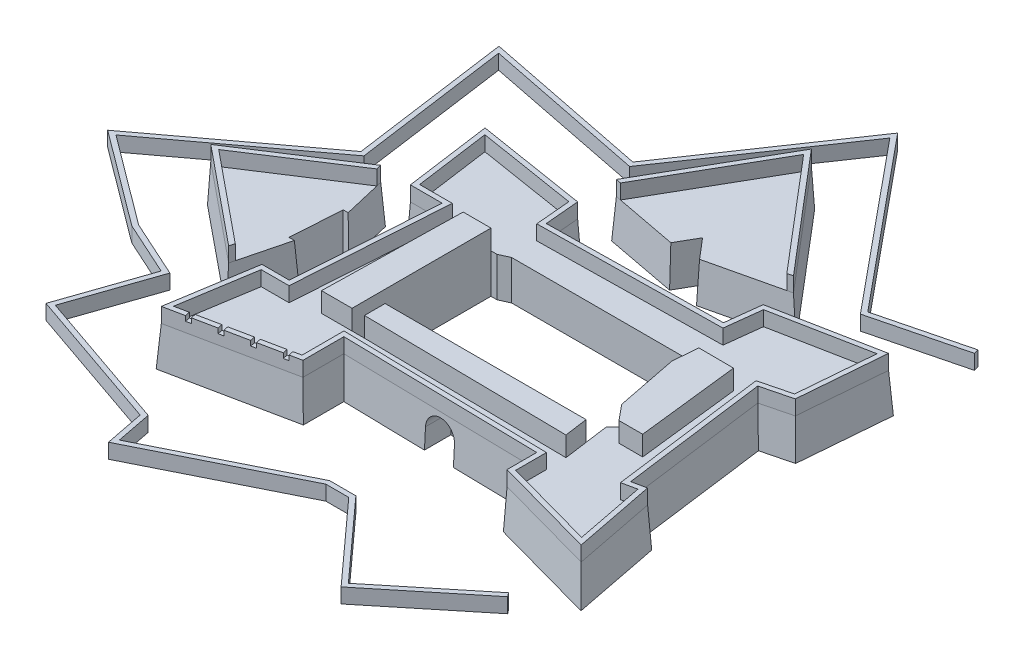
from build123d import *

# Parameters (mm, degrees)
BOSS_EXTRUDE2_DEPTH           = 4000
BOSS_EXTRUDE2_DRAFT           = 3
BOSS_EXTRUDE2_PROFILE_2_DEPTH = 4000
BOSS_EXTRUDE2_PROFILE_2_DRAFT = 3
BOSS_EXTRUDE2_PROFILE_3_DEPTH = 4000
BOSS_EXTRUDE2_PROFILE_3_DRAFT = 3
CUT_EXTRUDE8_DEPTH            = 90232.910730358
CUT_EXTRUDE8_DEPTH_BACK       = 9000
BOSS_EXTRUDE8_DEPTH           = 1500
BOSS_EXTRUDE3_START           = 4000
BOSS_EXTRUDE3_DEPTH           = 1500
BOSS_EXTRUDE4_START           = 4000
BOSS_EXTRUDE4_DEPTH           = 1500
BOSS_EXTRUDE5_START           = 4000
BOSS_EXTRUDE5_DEPTH           = 1500
CUT_EXTRUDE9_DEPTH            = 11000
SKETCH12_W                    = 500
SKETCH12_H                    = 500
CUT_EXTRUDE10_DEPTH           = 500
LPATTERN1_COUNT               = 4
LPATTERN1_PITCH               = 2800
BOSS_EXTRUDE7_DEPTH           = 6000


with BuildPart() as part:
    # Sketch5 → Boss-Extrude2 (with draft: the straight prism first)
    with BuildSketch(Plane(origin=(0, 0, 0), x_dir=(1, 0, 0), z_dir=(0, 1, 0))):
        Polygon((24221.147231465, 12812.777238771), (36613.382745291, 15360.254637852), (36613.382745291, 19466.636116967), (56159.669846807, 19081.326574374), (56159.669846807, 16120.695652503), (67033.976356316, 13116.953644631), (65285.659888842, 22049.569248776), (63878.146145515, 21747.95916092), (61977.043608887, 36196.338439289), (64980.785616759, 36956.77945394), (65747.322139372, 46120.093680485), (54681.474863666, 43954.255153895), (54258.567310179, 40378.76401987), (36920.512176137, 40112.609664742), (36613.382745291, 43579.189822963), (24972.576970271, 45446.698770827), (26254.199807291, 36196.338439289), (29430.168181824, 36196.338439289), (28473.81693967, 22090.157617513), (25709.497024846, 22090.157617513), align=None)
    extrude(amount=BOSS_EXTRUDE2_DEPTH)
    # Boss-Extrude2: the draft: its side faces are tilted about the plane it starts from
    boss_extrude2_sides = [part.faces().sort_by_distance(p)[0] for p in [
        (30417.264988378, 2000, -14086.515938311),
        (36613.382745291, 2000, -17413.445377409),
        (46386.526296049, 2000, -19273.981345671),
        (56159.669846807, 2000, -17601.011113438),
        (61596.823101562, 2000, -14618.824648567),
        (66159.818122579, 2000, -17583.261446704),
        (64581.903017178, 2000, -21898.764204848),
        (62927.594877201, 2000, -28972.148800105),
        (63478.914612823, 2000, -36576.558946615),
        (65364.053878065, 2000, -41538.436567213),
        (60214.398501519, 2000, -45037.17441719),
        (54470.021086923, 2000, -42166.509586883),
        (45589.539743158, 2000, -40245.686842306),
        (36766.947460714, 2000, -41845.899743852),
        (30792.979857781, 2000, -44512.944296895),
        (25613.388388781, 2000, -40821.518605058),
        (27842.183994557, 2000, -36196.338439289),
        (28951.992560747, 2000, -29143.248028401),
        (27091.656982258, 2000, -22090.157617513),
        (24965.322128155, 2000, -17451.467428142),
    ]]
    draft(boss_extrude2_sides, Plane(origin=(0, 0, 0), x_dir=(1, 0, 0), z_dir=(0, 1, 0)), BOSS_EXTRUDE2_DRAFT)

    # Sketch5_4 → Cut-Extrude8 (cut, two sides)
    with BuildSketch(Plane(origin=(0, 0, 0), x_dir=(1, 0, 0), z_dir=(0, 1, 0))) as cut_extrude8_sk:
        Polygon((35428.968084809, 22093.341525096), (31723.721045337, 22093.341525096), (32001.728794941, 36196.338439289), (35428.968084809, 36196.338439289), align=None)
        Polygon((36084.02706002, 22093.341525096), (35428.968084809, 22093.341525096), (35428.968084809, 36196.338439289), (36458.730662276, 36657.954872095), (54258.567310179, 36657.954872095), (55973.233378537, 36196.338439289), (55973.233378537, 34396.808595444), (56951.330931415, 27337.200618605), (56159.669846807, 26560.044676759), (36084.02706002, 26560.044676759), align=None)
        Polygon((59443.059424266, 36196.338439289), (60646.271833248, 25773.58180428), (58239.847015285, 25773.58180428), (56951.330931415, 27337.200618605), (55973.233378537, 34396.808595444), (55973.233378537, 36196.338439289), align=None)
        Polygon((56817.379343917, 21812.899365358), (36084.02706002, 22093.341525096), (36084.02706002, 26560.044676759), (56159.669846807, 26560.044676759), align=None)
    extrude(amount=CUT_EXTRUDE8_DEPTH, mode=Mode.SUBTRACT)
    extrude(cut_extrude8_sk.sketch, amount=-CUT_EXTRUDE8_DEPTH_BACK, mode=Mode.SUBTRACT)

    # Sketch7_4 → Boss-Extrude4 (add)
    with BuildSketch(Plane(origin=(0, 0, 0), x_dir=(1, 0, 0), z_dir=(0, 1, 0)).offset(BOSS_EXTRUDE4_START)):
        Polygon((28669.716997515, 21880.526500381), (25888.177990487, 21880.526500381), (24476.204351751, 13079.224152258), (36403.751628159, 15531.175382463), (36403.751628159, 19680.440349773), (56369.300963939, 19286.866028357), (56369.300963939, 16280.272060367), (66763.160475319, 13409.240936594), (65120.921538659, 21799.878114852), (63699.941915328, 21495.382481281), (61744.885798014, 36353.808972866), (64784.351704009, 37123.294012359), (65515.290885637, 45861.071279535), (54871.705572801, 43777.879043348), (54445.20057926, 40171.97318886), (36728.895454385, 39900.012364574), (36418.977542885, 43398.066197205), (25219.105564891, 45194.837102765), (26436.789304251, 36405.969556421), (29654.492797924, 36405.969556421), align=None)
        Polygon((35955.293512896, 42966.060614647), (25807.111291314, 44594.11123843), (26872.291197907, 36905.969556421), (30189.538880703, 36905.969556421), (29136.966470124, 21380.526500381), (26314.3574816, 21380.526500381), (25084.551823671, 13714.737899291), (35903.751628159, 15938.845643799), (35903.751628159, 20190.393823596), (56869.300963939, 19777.106830377), (56869.300963939, 16660.884466691), (66117.226120005, 14106.387657847), (64727.997166463, 21204.329282836), (63274.899506011, 20892.951212739), (61191.156432714, 36729.3985698), (64315.828911598, 37520.454893568), (64961.863377094, 45243.266049822), (55325.432843202, 43357.196959123), (54890.347443984, 39678.747674825), (36271.86234696, 39392.937596582), align=None, mode=Mode.SUBTRACT)
    extrude(amount=BOSS_EXTRUDE4_DEPTH)

    # Sketch9 → Cut-Extrude9 (cut)
    with BuildSketch(Plane.XY.offset(-30000)):
        with BuildLine():
            Line((44964.636947484, 0), (44964.636947484, 2000))
            ThreePointArc((44964.636947484, 2000), (46464.636947484, 3500), (47964.636947484, 2000))
            Line((47964.636947484, 2000), (47964.636947484, 0))
            Line((47964.636947484, 0), (44964.636947484, 0))
        make_face()
    extrude(amount=CUT_EXTRUDE9_DEPTH, mode=Mode.SUBTRACT)

    # Sketch12 → Cut-Extrude10 (cut)
    with BuildSketch(Plane(origin=(-1587.279743094, 0, -7721.342065621), x_dir=(0.9795173421549181, 0, -0.2013598182800262), z_dir=(0.20135981828002616, 0, 0.979517342154918))):
        with Locations((37340.818301027, 5250)):
            Rectangle(SKETCH12_W, SKETCH12_H)
    cut_extrude10 = extrude(amount=-CUT_EXTRUDE10_DEPTH, mode=Mode.SUBTRACT)

    # LPattern1: Cut-Extrude10 ×4
    with Locations(*[Vector(-0.9795173421549181, 0, 0.2013598182800262) * (i * LPATTERN1_PITCH) for i in range(1, LPATTERN1_COUNT)]):
        add(cut_extrude10, mode=Mode.SUBTRACT)

    # Sketch8 → Boss-Extrude7 (add)
    with BuildSketch(Plane(origin=(0, 0, 0), x_dir=(1, 0, 0), z_dir=(0, 1, 0))):
        Polygon((32001.728794941, 36196.338439289), (34821.189503531, 36196.338439289), (34821.189503531, 22093.341525096), (31723.721045337, 22093.341525096), align=None)
        Polygon((36084.02706002, 22093.341525096), (56817.379343917, 21812.899365358), (56488.524595362, 24186.472021059), (36084.02706002, 24186.472021059), align=None)
        Polygon((59443.059424266, 36196.338439289), (60646.271833248, 25773.58180428), (58239.847015285, 25773.58180428), (56951.330931415, 27337.200618605), (55694.285613264, 33692.829318225), (55908.720433738, 36213.706389818), align=None)
    extrude(amount=BOSS_EXTRUDE7_DEPTH)


with BuildPart() as body_2:
    # Sketch5 → Boss-Extrude2 profile 2 (with draft: the straight prism first)
    with BuildSketch(Plane(origin=(0, 0, 0), x_dir=(1, 0, 0), z_dir=(0, 1, 0))):
        Polygon((22700.265202163, 21443.78275506), (24202.136206099, 27337.200618605), (23612.794419744, 27337.200618605), (23916.970825604, 32089.956960174), (24487.301586593, 32089.956960174), (23346.640064616, 36956.77945394), (12396.289453642, 29846.655966953), align=None)
    extrude(amount=BOSS_EXTRUDE2_PROFILE_2_DEPTH)
    # Boss-Extrude2 profile 2: the draft: its side faces are tilted about the plane it starts from
    boss_extrude2_profile_2_sides = [body_2.faces().sort_by_distance(p)[0] for p in [
        (23451.200704131, 2000, -24390.491686832),
        (23907.465312921, 2000, -27337.200618605),
        (23764.882622674, 2000, -29713.578789389),
        (24202.136206099, 2000, -32089.956960174),
        (23916.970825604, 2000, -34523.368207057),
        (17871.464759129, 2000, -33401.717710447),
        (17548.277327902, 2000, -25645.219361007),
    ]]
    draft(boss_extrude2_profile_2_sides, Plane(origin=(0, 0, 0), x_dir=(1, 0, 0), z_dir=(0, 1, 0)), BOSS_EXTRUDE2_PROFILE_2_DRAFT)

    # Sketch7_6 → Boss-Extrude5 (add)
    with BuildSketch(Plane(origin=(0, 0, 0), x_dir=(1, 0, 0), z_dir=(0, 1, 0)).offset(BOSS_EXTRUDE5_START)):
        Polygon((23210.610198856, 36618.509706606), (12751.589675404, 29827.409575058), (22578.229585565, 21813.802858654), (22714.35680761, 22347.972970475), (13599.031187481, 29781.504195747), (23331.878959981, 36101.096325807), align=None)
    extrude(amount=BOSS_EXTRUDE5_DEPTH)


with BuildPart() as body_3:
    # Sketch5 → Boss-Extrude2 profile 3 (with draft: the straight prism first)
    with BuildSketch(Plane(origin=(0, 0, 0), x_dir=(1, 0, 0), z_dir=(0, 1, 0))):
        Polygon((36084.02706002, 47184.711100996), (43346.233299116, 45803.211873316), (44448.538693732, 47720.822016325), (46076.764033341, 45803.211873316), (54258.567310179, 47720.822016325), (43604.788694919, 60268.098758067), align=None)
    extrude(amount=BOSS_EXTRUDE2_PROFILE_3_DEPTH)
    # Boss-Extrude2 profile 3: the draft: its side faces are tilted about the plane it starts from
    boss_extrude2_profile_3_sides = [body_3.faces().sort_by_distance(p)[0] for p in [
        (39715.130179568, 2000, -46493.961487156),
        (43897.385996424, 2000, -46762.016944821),
        (45262.651363537, 2000, -46762.016944821),
        (50167.66567176, 2000, -46762.016944821),
        (48931.678002549, 2000, -53994.460387196),
        (39844.40787747, 2000, -53726.404929532),
    ]]
    draft(boss_extrude2_profile_3_sides, Plane(origin=(0, 0, 0), x_dir=(1, 0, 0), z_dir=(0, 1, 0)), BOSS_EXTRUDE2_PROFILE_3_DRAFT)

    # Sketch7 → Boss-Extrude3 (add)
    with BuildSketch(Plane(origin=(0, 0, 0), x_dir=(1, 0, 0), z_dir=(0, 1, 0)).offset(BOSS_EXTRUDE3_START)):
        Polygon((36932.436046199, 47236.70759238), (36412.562863177, 47335.603764864), (43637.955042603, 59905.156085089), (53876.73067046, 47846.640891682), (53329.672426153, 47718.424115673), (43717.061494303, 59039.486240978), align=None)
    extrude(amount=BOSS_EXTRUDE3_DEPTH)


with BuildPart() as body_4:
    # Sketch5_6 → Boss-Extrude8 (new body)
    with BuildSketch(Plane(origin=(0, 0, 0), x_dir=(1, 0, 0), z_dir=(0, 1, 0))):
        Polygon((54258.567310179, 1546.843606716), (63580.182900737, 9139.424700384), (63264.41664934, 9527.099402265), (54310.67496669, 2234.156547366), (47001.206294489, 10305.078249172), (44330.668211136, 10305.078249172), (30098.838301686, 3200.181479544), (29387.362945299, 6835.299027577), (14993.993678286, 11802.92956724), (16054.681746074, 14876.200599556), (17977.718880796, 20448.068992994), (12159.337222509, 23091.171139248), (3103.722947215, 29846.436428417), (17531.283631937, 40597.258986746), (15333.683541619, 56458.862036314), (31950.603856265, 53147.392889184), (42647.210782744, 68855.459777976), (56632.98216886, 51883.676851905), (65870.033072857, 54222.170751651), (65747.322139372, 54706.878938918), (56817.379343917, 52446.13392741), (42609.140070311, 69687.882419931), (31723.658282012, 53702.45103757), (14741.932604944, 57086.619678919), (16995.436710251, 40821.518605058), (2267.21513849, 29846.655966953), (11903.523676148, 22658.207055457), (17356.617773435, 20181.043204968), (15582.039798208, 15039.325058534), (14358.227271441, 11493.412078351), (28951.992560747, 6456.61820508), (29734.344587685, 2459.372824298), (44448.538693732, 9805.078249172), (46779.457781313, 9805.078249172), align=None)
    extrude(amount=BOSS_EXTRUDE8_DEPTH)


solid = Compound([part.part, body_2.part, body_3.part, body_4.part])
